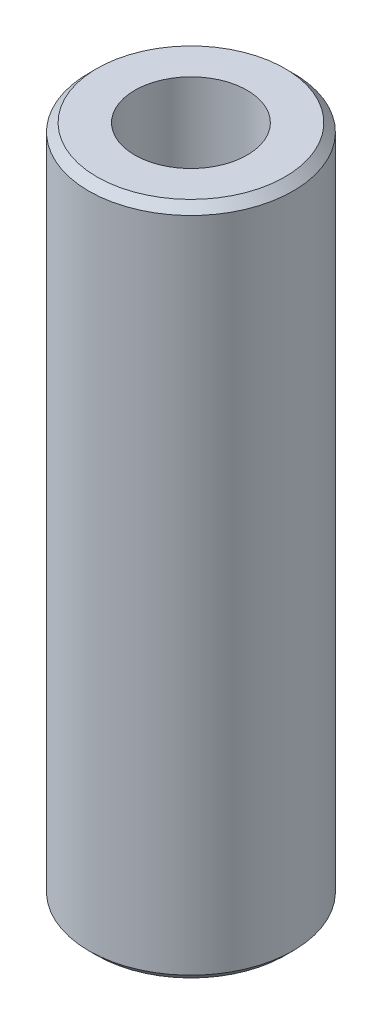
from build123d import *

# Parameters (mm, degrees)
SKETCH1_R           = 5
SKETCH1_R_2         = 2.75
BOSS_EXTRUDE1_DEPTH = 16.5
CHAMFER1_SIZE       = 0.4


with BuildPart() as part:
    # Sketch1 → Boss-Extrude1 (new body, symmetric)
    with BuildSketch(Plane(origin=(0, 0, 0), x_dir=(1, 0, 0), z_dir=(0, 1, 0))):
        Circle(SKETCH1_R)
        Circle(SKETCH1_R_2, mode=Mode.SUBTRACT)
    extrude(amount=BOSS_EXTRUDE1_DEPTH, both=True)

    # Chamfer1
    chamfer1_edges = [part.edges().sort_by_distance(p)[0] for p in [
        (-5, -16.5, 0),
        (-5, 16.5, 0),
    ]]
    chamfer(chamfer1_edges, length=CHAMFER1_SIZE)


solid = part.part
